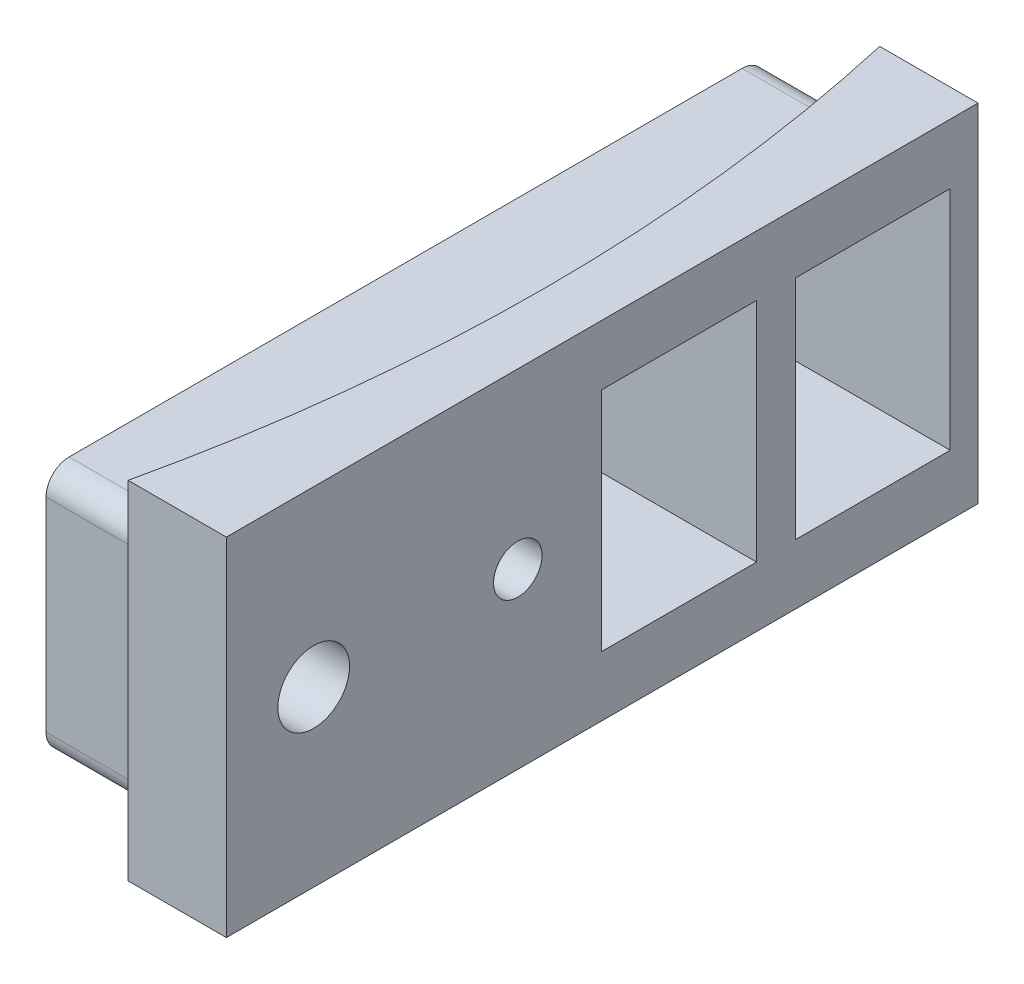
from build123d import *

# Parameters (mm, degrees)
BOSS_EXTRUDE1_DEPTH = 30
SKETCH2_W           = 62.2
SKETCH2_H           = 21.6
BOSS_EXTRUDE2_DEPTH = 17
SKETCH2_6_R         = 2.1
SKETCH2_6_R_2       = 3.1
SKETCH2_6_W         = 13.4
SKETCH2_6_H         = 19.6
CUT_EXTRUDE3_DEPTH  = 17
CUT_EXTRUDE5_START  = -7
SKETCH2_8_W         = 7.5
SKETCH2_8_H         = 7.5
SKETCH2_8_R         = 2.1
SKETCH2_8_W_2       = 10.3
SKETCH2_8_H_2       = 11
SKETCH2_8_R_2       = 3.1
CUT_EXTRUDE5_DEPTH  = 10
FILLET1_R           = 2


with BuildPart() as part:
    # Sketch1 → Boss-Extrude1 (new body)
    with BuildSketch(Plane(origin=(0, 0, 0), x_dir=(1, 0, 0), z_dir=(0, 1, 0))):
        with BuildLine():
            Line((152.287802769, 32.5), (143.787802769, 32.5))
            ThreePointArc((143.787802769, 32.5), (146.505394389, 16.350891105), (147.415, 0))
            ThreePointArc((147.415, 0), (146.505394389, -16.350891105), (143.787802769, -32.5))
            Line((143.787802769, -32.5), (152.287802769, -32.5))
            Line((152.287802769, -32.5), (152.287802769, 32.5))
        make_face()
    extrude(amount=BOSS_EXTRUDE1_DEPTH)

    # Sketch2 → Boss-Extrude2 (add)
    with BuildSketch(Plane(origin=(152.287802769, 0, 0), x_dir=(0, 0, -1), z_dir=(1, 0, 0))):
        with Locations((0, 15)):
            Rectangle(SKETCH2_W, SKETCH2_H)
    extrude(amount=-BOSS_EXTRUDE2_DEPTH)

    # Sketch2_6 → Cut-Extrude3 (cut)
    with BuildSketch(Plane(origin=(152.287802769, 0, 0), x_dir=(0, 0, -1), z_dir=(1, 0, 0))):
        with Locations((-7.3, 15)):
            Circle(SKETCH2_6_R)
        with Locations((-24.95, 15)):
            Circle(SKETCH2_6_R_2)
        with Locations((23.4, 15)):
            Rectangle(SKETCH2_6_W, SKETCH2_6_H)
        with Locations((6.65, 15)):
            Rectangle(SKETCH2_6_W, SKETCH2_6_H)
    extrude(amount=-CUT_EXTRUDE3_DEPTH, mode=Mode.SUBTRACT)

    # Sketch2_8 → Cut-Extrude5 (cut)
    with BuildSketch(Plane(origin=(152.287802769, 0, 0), x_dir=(0, 0, -1), z_dir=(1, 0, 0)).offset(CUT_EXTRUDE5_START)):
        with Locations((-7.3, 15)):
            Rectangle(SKETCH2_8_W, SKETCH2_8_H)
        with Locations((-7.3, 15)):
            Circle(SKETCH2_8_R, mode=Mode.SUBTRACT)
        with Locations((-24.95, 15)):
            Rectangle(SKETCH2_8_W_2, SKETCH2_8_H_2)
        with Locations((-24.95, 15)):
            Circle(SKETCH2_8_R_2, mode=Mode.SUBTRACT)
    extrude(amount=-CUT_EXTRUDE5_DEPTH, mode=Mode.SUBTRACT)

    # Fillet1
    fillet1_edges = [part.edges().sort_by_distance(p)[0] for p in [
        (139.692447908, 25.8, 31.1),
        (139.692447908, 25.8, -31.1),
        (139.692447908, 4.2, -31.1),
        (139.692447908, 4.2, 31.1),
    ]]
    fillet(fillet1_edges, radius=FILLET1_R)


solid = part.part
